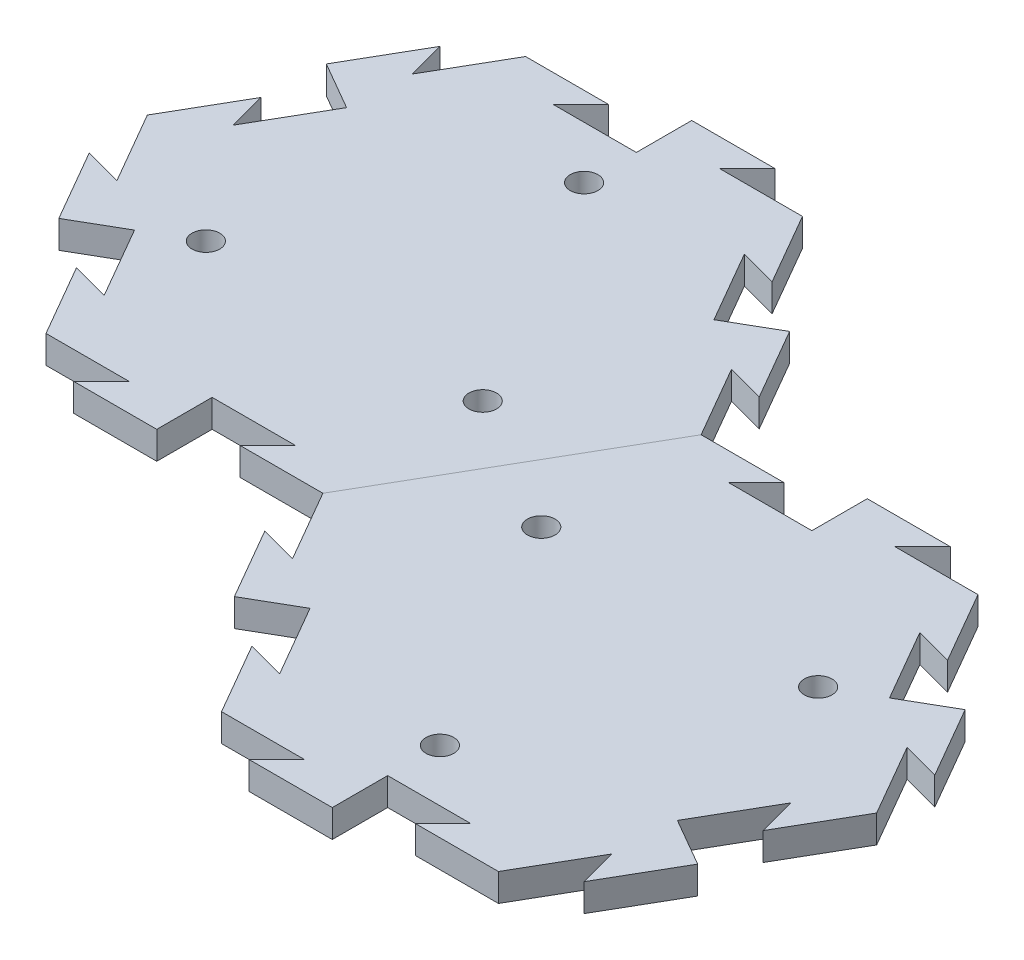
from build123d import *

# Parameters (mm, degrees)
BOSS_EXTRUDE1_DEPTH = 6.35
SKETCH9_R           = 3.175
CUT_EXTRUDE3_DEPTH  = 85.242269675
CIRPATTERN6_COUNT   = 3
CUT_EXTRUDE4_DEPTH  = 194.232075495
BOSS_EXTRUDE4_DEPTH = 6.35
CIRPATTERN7_COUNT   = 6
CUT_EXTRUDE5_DEPTH  = 194.232075495
BOSS_EXTRUDE5_DEPTH = 6.35
CIRPATTERN8_COUNT   = 6


with BuildPart() as part:
    # Sketch1 → Boss-Extrude1 (new body)
    with BuildSketch(Plane(origin=(0, 0, 0), x_dir=(1, 0, 0), z_dir=(0, 1, 0))):
        Polygon((63.5, 0), (31.75, 54.99261314), (-31.75, 54.99261314), (-63.5, 0), (-31.75, -54.99261314), (31.75, -54.99261314), align=None)
    extrude(amount=-BOSS_EXTRUDE1_DEPTH)

    # Sketch9 → Cut-Extrude3 (cut, through all)
    with BuildSketch(Plane(origin=(0, 0, 0), x_dir=(1, 0, 0), z_dir=(0, 1, 0))):
        with Locations((-31.75, -18.330871047)):
            Circle(SKETCH9_R)
    cut_extrude3 = extrude(amount=-CUT_EXTRUDE3_DEPTH, mode=Mode.SUBTRACT)

    # CirPattern6: Cut-Extrude3 ×3 about axis
    cirpattern6_axis = Axis((0, 0, 0), (0, 1, 0))
    for i in range(1, CIRPATTERN6_COUNT):
        add(cut_extrude3.rotate(cirpattern6_axis, i * 360 / CIRPATTERN6_COUNT), mode=Mode.SUBTRACT)


with BuildPart() as body_2:
    # Mirror3: mirrored copy
    add(part.part.mirror(Plane(origin=(31.75, -6.35, 54.99261314), x_dir=(-0.4999999999999997, 0, 0.8660254037844387), z_dir=(0.8660254037844387, 0, 0.49999999999999983))))

    # Sketch13 → Cut-Extrude5 (cut, through all)
    with BuildSketch(Plane(origin=(0, 0, 0), x_dir=(1, 0, 0), z_dir=(0, 1, 0))):
        Polygon((136.525, -16.497783942), (127.850738686, -14.173522628), (137.375738686, -30.67130657), (142.875, -27.49630657), align=None)
    cut_extrude5 = extrude(amount=-CUT_EXTRUDE5_DEPTH, mode=Mode.SUBTRACT)

    # Sketch14 → Boss-Extrude5 (add)
    with BuildSketch(Plane(origin=(0, 0, 0), x_dir=(1, 0, 0), z_dir=(0, 1, 0))):
        Polygon((142.875, -27.49630657), (148.374261314, -24.32130657), (157.899261314, -40.819090512), (149.225, -38.494829198), align=None)
    boss_extrude5 = extrude(amount=-BOSS_EXTRUDE5_DEPTH)

    # CirPattern8: Cut-Extrude5, Boss-Extrude5 ×6 about axis, 1 skipped
    cirpattern8_axis = Axis((95.25, 0, 54.99261314), (0, 1, 0))
    add([cut_extrude5.rotate(cirpattern8_axis, i * 360 / CIRPATTERN8_COUNT) for i in range(1, CIRPATTERN8_COUNT) if i not in (2,)], mode=Mode.SUBTRACT)
    add([boss_extrude5.rotate(cirpattern8_axis, i * 360 / CIRPATTERN8_COUNT) for i in range(1, CIRPATTERN8_COUNT) if i not in (2,)])


with BuildPart() as part_1:
    add(part.part)

    # Sketch10 → Cut-Extrude4 (cut, through all)
    with BuildSketch(Plane(origin=(0, 0, 0), x_dir=(1, 0, 0), z_dir=(0, 1, 0))):
        Polygon((41.275, 38.494829198), (32.600738686, 40.819090512), (42.125738686, 24.32130657), (47.625, 27.49630657), align=None)
    cut_extrude4 = extrude(amount=-CUT_EXTRUDE4_DEPTH, mode=Mode.SUBTRACT)

    # Sketch11 → Boss-Extrude4 (add)
    with BuildSketch(Plane(origin=(0, 0, 0), x_dir=(1, 0, 0), z_dir=(0, 1, 0))):
        Polygon((47.625, 27.49630657), (53.124261314, 30.67130657), (62.649261314, 14.173522628), (53.975, 16.497783942), align=None)
    boss_extrude4 = extrude(amount=-BOSS_EXTRUDE4_DEPTH)

    # CirPattern7: Cut-Extrude4, Boss-Extrude4 ×6 about axis, 1 skipped
    cirpattern7_axis = Axis((0, 0, 0), (0, 1, 0))
    add([cut_extrude4.rotate(cirpattern7_axis, i * 360 / CIRPATTERN7_COUNT) for i in range(1, CIRPATTERN7_COUNT) if i not in (5,)], mode=Mode.SUBTRACT)
    add([boss_extrude4.rotate(cirpattern7_axis, i * 360 / CIRPATTERN7_COUNT) for i in range(1, CIRPATTERN7_COUNT) if i not in (5,)])


solid = Compound([body_2.part, part_1.part])
